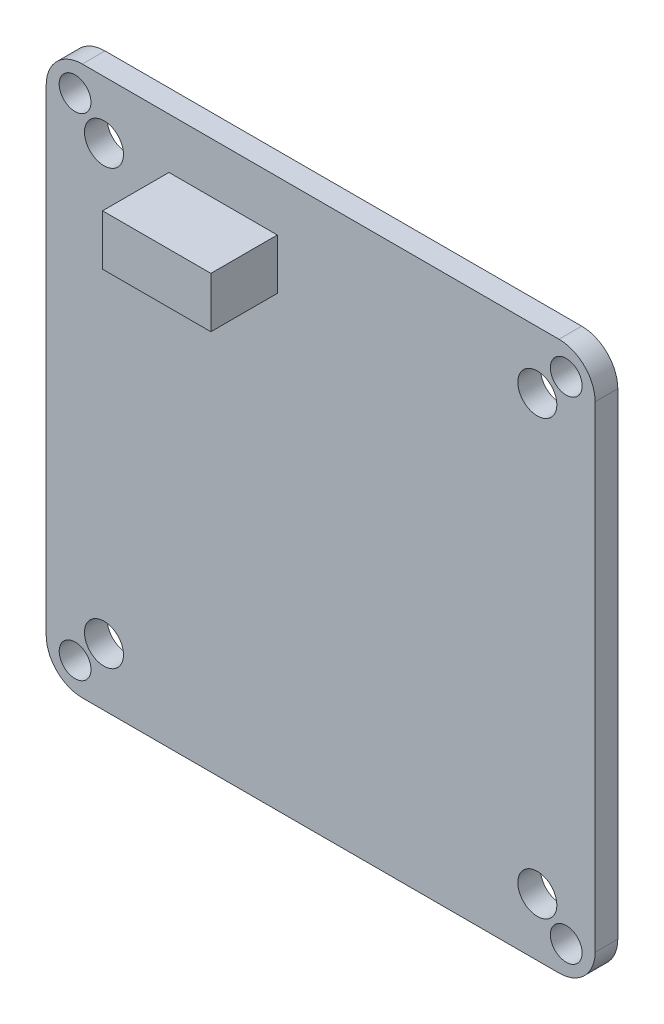
from build123d import *

# Parameters (mm, degrees)
SKETCH1_W              = 38
SKETCH1_H              = 38
BOSS_EXTRUDE1_DEPTH    = 1.57
FILLET1_R              = 2.5
M2_CLEARANCE_HOLE1_D   = 2.2
M2_5_CLEARANCE_HOLE1_D = 2.7
SKETCH6_W              = 7.5
SKETCH6_H              = 3.5
BOSS_EXTRUDE2_DEPTH    = 4.6


with BuildPart() as part:
    # Sketch1 → Boss-Extrude1 (new body)
    with BuildSketch(Plane.XY):
        Rectangle(SKETCH1_W, SKETCH1_H)
    extrude(amount=BOSS_EXTRUDE1_DEPTH)

    # Fillet1
    fillet1_edges = [part.edges().sort_by_distance(p)[0] for p in [
        (19, -19, 0.785),
        (-19, -19, 0.785),
        (-19, 19, 0.785),
        (19, 19, 0.785),
    ]]
    fillet(fillet1_edges, radius=FILLET1_R)

    # M2 Clearance Hole1 (through all)
    with Locations(Plane.XY.offset(1.57)):
        with Locations((-17, 17), (17, -17), (-17, -17), (17, 17)):
            Hole(M2_CLEARANCE_HOLE1_D / 2)

    # M2.5 Clearance Hole1 (through all)
    with Locations(Plane.XY.offset(1.57)):
        with Locations((-15, 15), (15, -15), (-15, -15), (15, 15)):
            Hole(M2_5_CLEARANCE_HOLE1_D / 2)


with BuildPart() as body_2:
    # Sketch6 → Boss-Extrude2 (new body)
    with BuildSketch(Plane.XY.offset(1.57)):
        with Locations((-6.75, 13.75)):
            Rectangle(SKETCH6_W, SKETCH6_H)
    extrude(amount=BOSS_EXTRUDE2_DEPTH)


solid = Compound([part.part, body_2.part])
